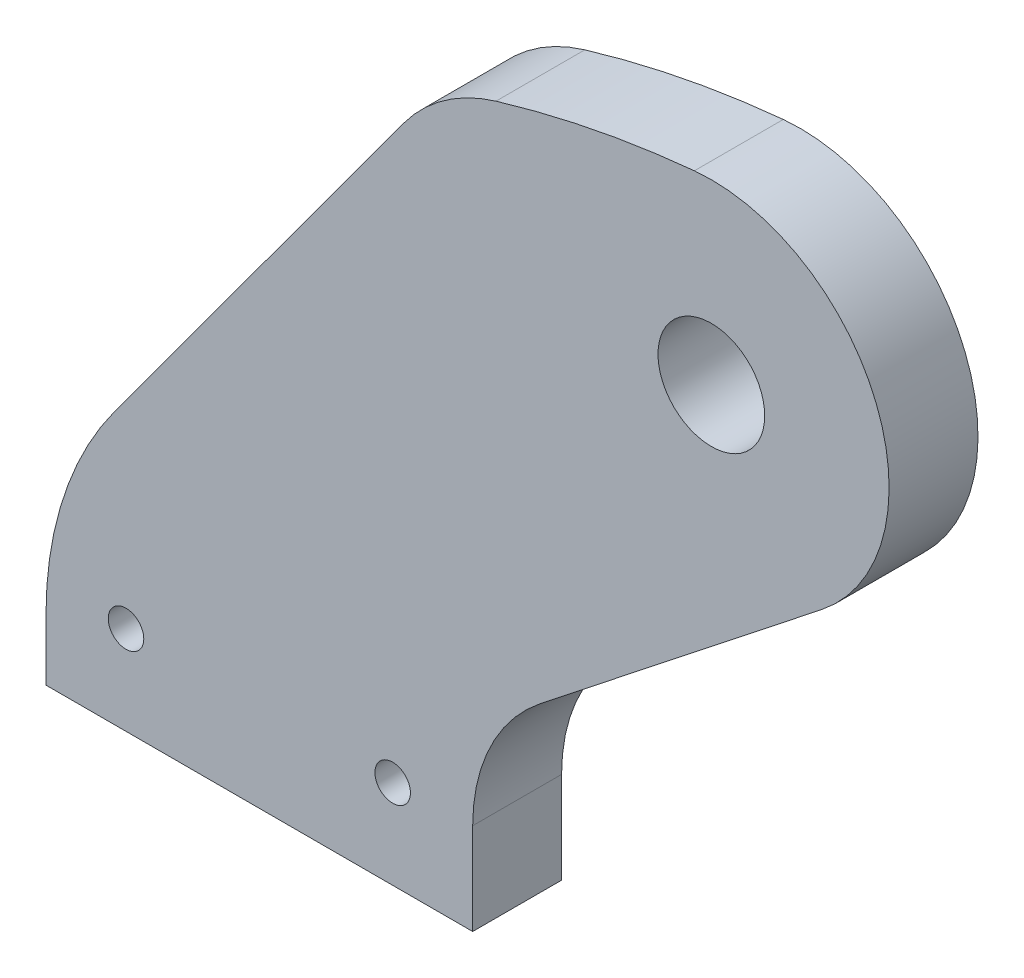
from build123d import *

# Parameters (mm, degrees)
SKETCH1_R      = 0.635
EXTRUDE1_DEPTH = 3.175
SKETCH2_R      = 1.905
EXTRUDE2_DEPTH = 4.175


with BuildPart() as part:
    # Sketch1 → Extrude1 (new body)
    with BuildSketch(Plane.XY):
        with BuildLine():
            Line((-7.62, 0), (7.62, 0))
            Line((7.62, 0), (7.62, 3.272777676))
            ThreePointArc((7.62, 3.272777676), (8.25562747, 6.041973695), (10.035258768, 8.256783238))
            Line((10.035258768, 8.256783238), (20.079071056, 16.186108729))
            ThreePointArc((20.079071056, 16.186108729), (22.036906124, 23.536555615), (15.53898187, 27.491194408))
            ThreePointArc((15.53898187, 27.491194408), (11.961099032, 26.970268702), (8.451534603, 26.101035293))
            ThreePointArc((8.451534603, 26.101035293), (6.615319821, 25.206255275), (5.1581845, 23.774797045))
            Line((5.1581845, 23.774797045), (-5.161343447, 9.702713481))
            ThreePointArc((-5.161343447, 9.702713481), (-6.989694731, 6.143656664), (-7.62, 2.192394953))
            Line((-7.62, 2.192394953), (-7.62, 0))
        make_face()
        with Locations((-4.7625, 3.175)):
            Circle(SKETCH1_R, mode=Mode.SUBTRACT)
        with Locations(Location((4.7625, 3.175, 0), (0, 0, 180))):  # turned: the seam where the file's is
            Circle(SKETCH1_R, mode=Mode.SUBTRACT)
    extrude(amount=EXTRUDE1_DEPTH)

    # Sketch2 → Extrude2 (cut, through all)
    with BuildSketch(Plane.XY.offset(3.175)):
        with Locations((16.144329824, 21.17011429)):
            Circle(SKETCH2_R)
    extrude(amount=-EXTRUDE2_DEPTH, mode=Mode.SUBTRACT)


solid = part.part
